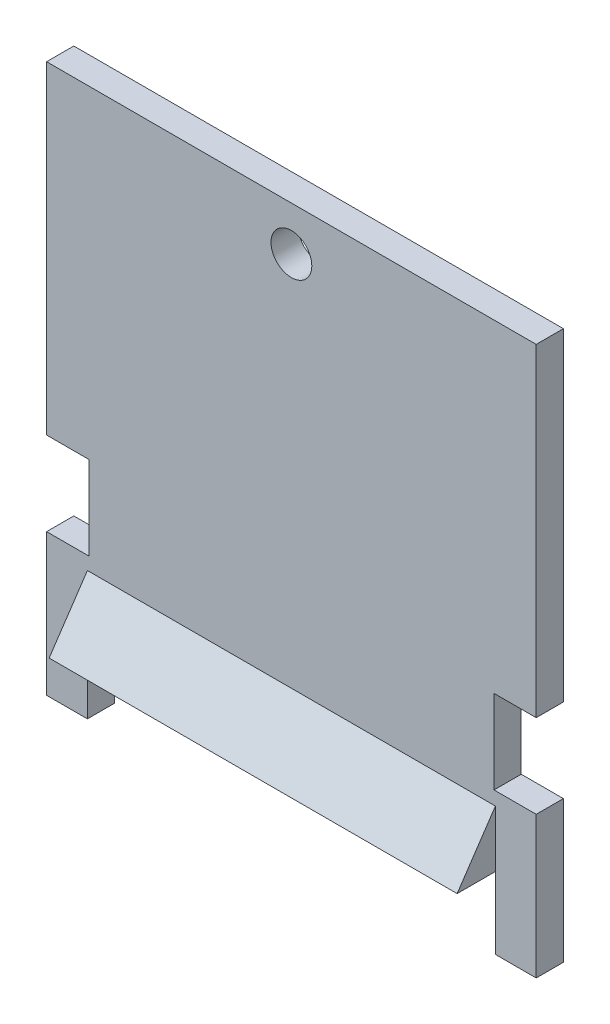
from build123d import *

# Parameters (mm, degrees)
BOSS_EXTRUDE1_DEPTH = 18
SKETCH2_R           = 1.5
SKETCH2_W           = 30
SKETCH2_H           = 2.78
CUT_EXTRUDE1_DEPTH  = 7.5
SKETCH3_W           = 3.1
SKETCH3_H           = 6.15
CUT_EXTRUDE2_DEPTH  = 7.5
SKETCH4_W           = 3
SKETCH4_H           = 7.645
CUT_EXTRUDE3_DEPTH  = 5.5
SKETCH5_W           = 6.5
SKETCH5_H           = 2.5
CUT_EXTRUDE4_DEPTH  = 30


with BuildPart() as part:
    # Sketch1 → Boss-Extrude1 (new body, symmetric)
    with BuildSketch(Plane(origin=(0, 0, 0), x_dir=(0, 0, -1), z_dir=(1, 0, 0))):
        Polygon((0, 0), (0, 40.35), (-2, 40.35), (-2, 9.45), (-6.5, 2.78), (-2, 2.78), (-2, 0), align=None)
    extrude(amount=BOSS_EXTRUDE1_DEPTH, both=True)

    # Sketch2 → Cut-Extrude1 (cut, through all)
    with BuildSketch(Plane(origin=(0, 0, 0), x_dir=(-1, 0, 0), z_dir=(0, 0, -1))):
        with Locations((0, 37.1)):
            Circle(SKETCH2_R)
        with Locations((0, 1.39)):
            Rectangle(SKETCH2_W, SKETCH2_H)
    extrude(amount=-CUT_EXTRUDE1_DEPTH, mode=Mode.SUBTRACT)

    # Sketch3 → Cut-Extrude2 (cut, through all)
    with BuildSketch(Plane(origin=(0, 0, 0), x_dir=(-1, 0, 0), z_dir=(0, 0, -1))):
        with Locations((-16.45, 13.5)):
            Rectangle(SKETCH3_W, SKETCH3_H)
        with Locations((16.45, 13.5)):
            Rectangle(SKETCH3_W, SKETCH3_H)
    extrude(amount=-CUT_EXTRUDE2_DEPTH, mode=Mode.SUBTRACT)

    # Sketch4 → Cut-Extrude3 (cut, through all)
    with BuildSketch(Plane.XY.offset(2)):
        with Locations((-16.5, 6.6025)):
            Rectangle(SKETCH4_W, SKETCH4_H)
        with Locations((16.5, 6.6025)):
            Rectangle(SKETCH4_W, SKETCH4_H)
    extrude(amount=CUT_EXTRUDE3_DEPTH, mode=Mode.SUBTRACT)

    # Sketch5 → Cut-Extrude4 (cut)
    with BuildSketch(Plane.ZY.offset(15)):
        with Locations((3.25, 4.03)):
            Rectangle(SKETCH5_W, SKETCH5_H)
    extrude(amount=-CUT_EXTRUDE4_DEPTH, mode=Mode.SUBTRACT)


solid = part.part
